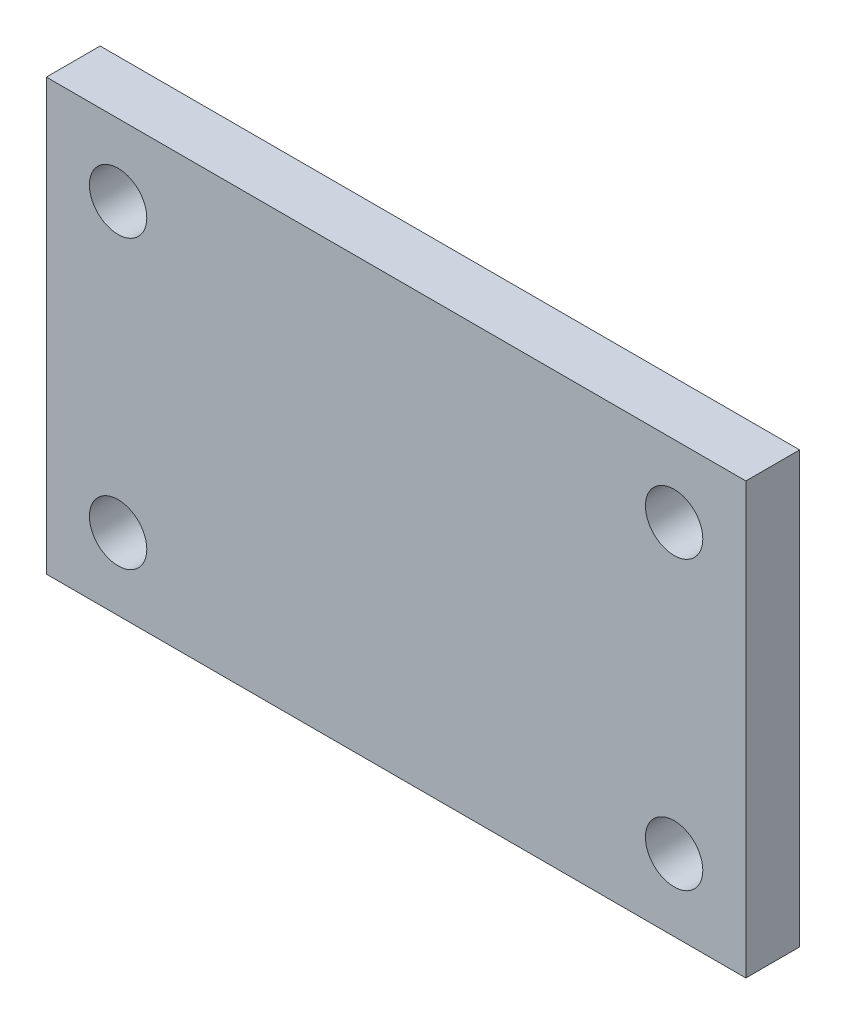
from build123d import *

# Parameters (mm, degrees)
SKETCH_1_W          = 39
SKETCH_1_H          = 20
SKETCH_1_R          = 1.6
EXTRUDE_1_DEPTH     = 3
SKETCH_2_W          = 39
SKETCH_2_H          = 3
EXTRUDE_2_DEPTH     = 4
SKETCH_3_R          = 1.6
CUT_EXTRUDE_1_DEPTH = 4


with BuildPart() as part:
    # ｽｹｯﾁ1 → ﾎﾞｽ - 押し出し1 (new body)
    with BuildSketch(Plane.XY):
        Rectangle(SKETCH_1_W, SKETCH_1_H)
        with Locations((15.5, 6)):
            Circle(SKETCH_1_R, mode=Mode.SUBTRACT)
        with BuildLine():
            ThreePointArc((-15.5, 7.6), (-14.36862915, 4.86862915), (-17.1, 6))
            Line((-17.1, 6), (-15.5, 6))
            Line((-15.5, 6), (-15.5, 7.6))
        make_face(mode=Mode.SUBTRACT)
    extrude(amount=EXTRUDE_1_DEPTH)

    # ｽｹｯﾁ2 → ﾎﾞｽ - 押し出し2 (add)
    with BuildSketch(Plane.XZ.offset(10)):
        with Locations((0, 1.5)):
            Rectangle(SKETCH_2_W, SKETCH_2_H)
    extrude(amount=EXTRUDE_2_DEPTH)

    # ｽｹｯﾁ3 → ｶｯﾄ - 押し出し1 (cut)
    with BuildSketch(Plane.XY.offset(3)):
        with Locations((-15.5, 6)):
            Circle(SKETCH_3_R)
        with Locations((-15.5, -10)):
            Circle(SKETCH_3_R)
        with Locations((15.5, -10)):
            Circle(SKETCH_3_R)
    extrude(amount=-CUT_EXTRUDE_1_DEPTH, mode=Mode.SUBTRACT)


solid = part.part
